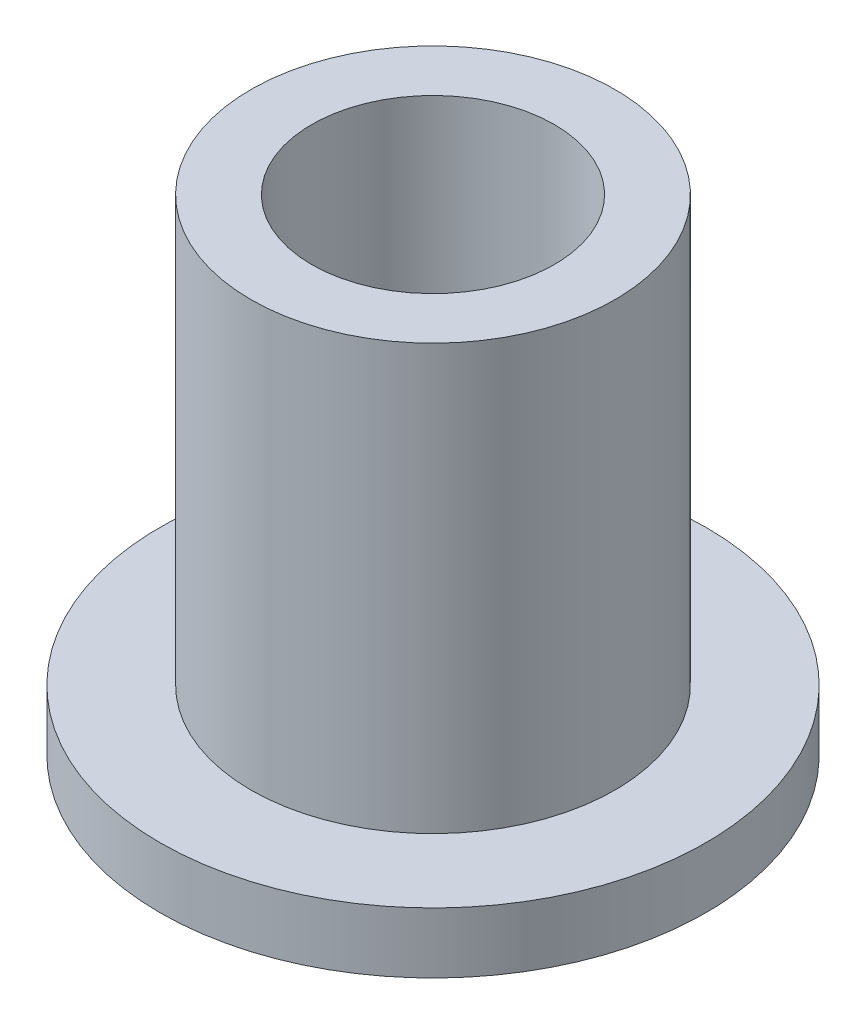
from build123d import *

# Parameters (mm, degrees)
SKETCH2_R           = 4.7625
SKETCH2_R_2         = 3.175
BOSS_EXTRUDE1_DEPTH = 12.7
SKETCH3_R           = 7.14375
SKETCH3_R_2         = 4.7625
BOSS_EXTRUDE2_DEPTH = 1.5875


with BuildPart() as part:
    # Sketch2 → Boss-Extrude1 (new body)
    with BuildSketch(Plane(origin=(0, 0, 0), x_dir=(1, 0, 0), z_dir=(0, 1, 0))):
        Circle(SKETCH2_R)
        Circle(SKETCH2_R_2, mode=Mode.SUBTRACT)
    extrude(amount=BOSS_EXTRUDE1_DEPTH)

    # Sketch3 → Boss-Extrude2 (add)
    with BuildSketch(Plane(origin=(0, 0, 0), x_dir=(1, 0, 0), z_dir=(0, 1, 0))):
        Circle(SKETCH3_R)
        Circle(SKETCH3_R_2, mode=Mode.SUBTRACT)
    extrude(amount=BOSS_EXTRUDE2_DEPTH)


solid = part.part
